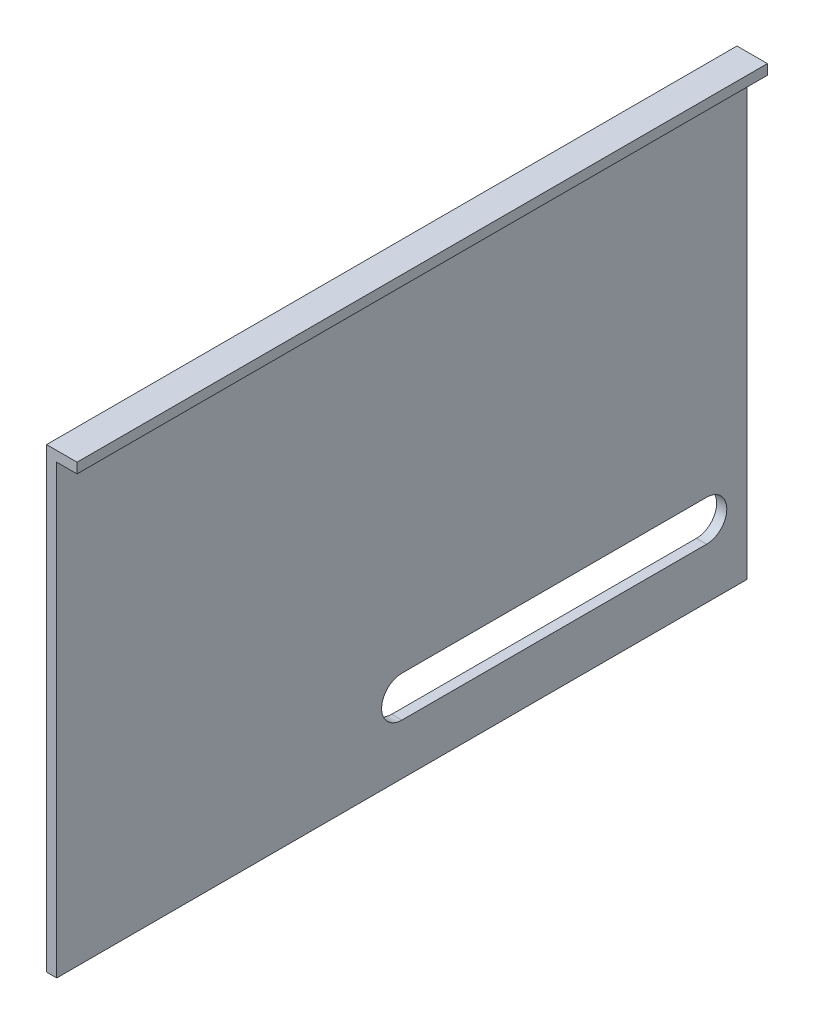
from build123d import *

# Parameters (mm, degrees)
SKETCH1_W           = 431.8
SKETCH1_H           = 285.75
BOSS_EXTRUDE1_DEPTH = 6.35
SKETCH2_W           = 431.8
SKETCH2_H           = 6.35
BOSS_EXTRUDE2_DEPTH = 12.7
CUT_EXTRUDE1_DEPTH  = 20.05


with BuildPart() as part:
    # Sketch1 → Boss-Extrude1 (new body)
    with BuildSketch(Plane(origin=(0, 0, 0), x_dir=(0, 0, -1), z_dir=(1, 0, 0))):
        Rectangle(SKETCH1_W, SKETCH1_H)
    extrude(amount=BOSS_EXTRUDE1_DEPTH)

    # Sketch2 → Boss-Extrude2 (add)
    with BuildSketch(Plane(origin=(6.35, 0, 0), x_dir=(0, 0, -1), z_dir=(1, 0, 0))):
        with Locations((0, 139.7)):
            Rectangle(SKETCH2_W, SKETCH2_H)
    extrude(amount=BOSS_EXTRUDE2_DEPTH)

    # Sketch3 → Cut-Extrude1 (cut, through all)
    with BuildSketch(Plane.ZY):
        with BuildLine():
            Line((-190.5, -85.725), (0, -85.725))
            ThreePointArc((0, -85.725), (12.7, -98.425), (0, -111.125))
            Line((0, -111.125), (-190.5, -111.125))
            ThreePointArc((-190.5, -111.125), (-203.2, -98.425), (-190.5, -85.725))
        make_face()
    extrude(amount=-CUT_EXTRUDE1_DEPTH, mode=Mode.SUBTRACT)


solid = part.part
